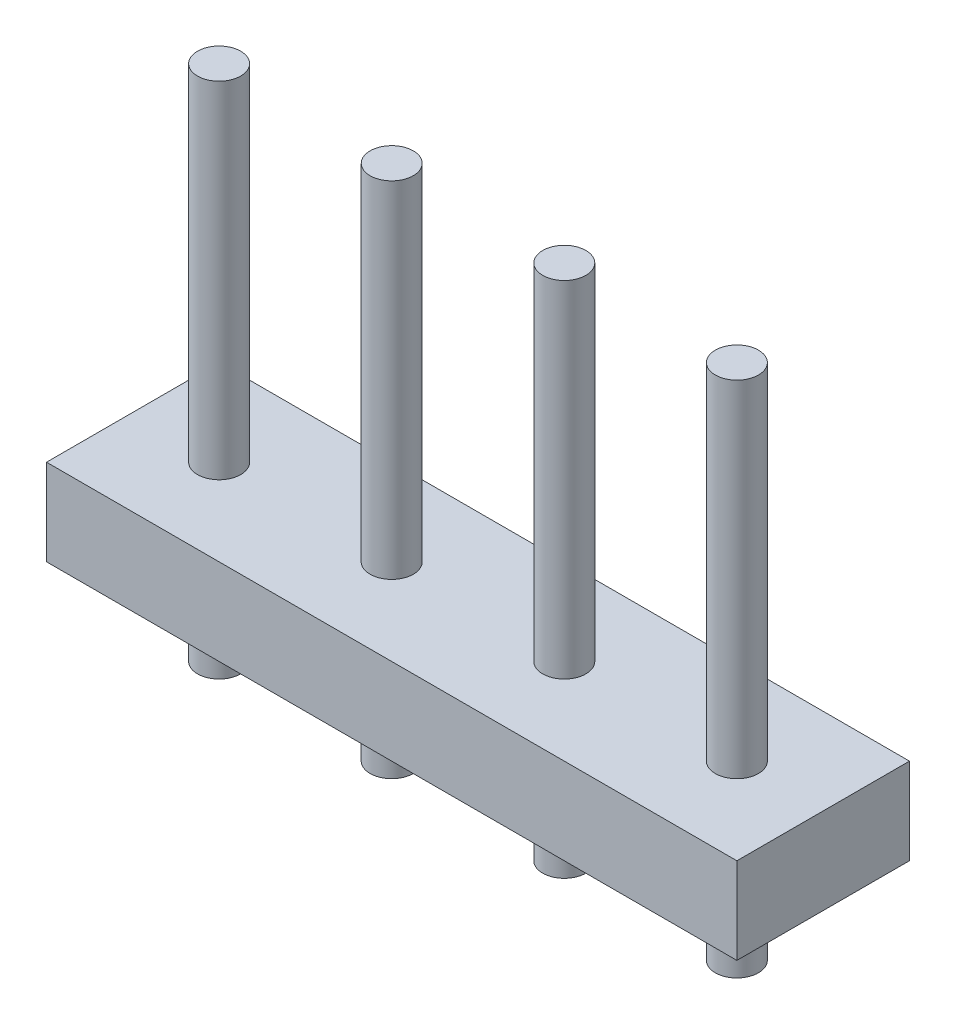
from build123d import *

# Parameters (mm, degrees)
SKETCH1_W           = 10.16
SKETCH1_H           = 2.54
EXTRUDE1_DEPTH      = 1.27
SKETCH2_R           = 0.3175
EXTRUDE2_DEPTH      = 5.08
EXTRUDE2_DEPTH_BACK = 2.54


with BuildPart() as part:
    # Sketch1 → Extrude1 (new body)
    with BuildSketch(Plane(origin=(0, 0, 0), x_dir=(1, 0, 0), z_dir=(0, 1, 0))):
        Rectangle(SKETCH1_W, SKETCH1_H)
    extrude(amount=EXTRUDE1_DEPTH)

    # Sketch2 → Extrude2 (add, two sides)
    with BuildSketch(Plane(origin=(0, 1.27, 0), x_dir=(1, 0, 0), z_dir=(0, 1, 0))) as extrude2_sk:
        with Locations(Location((-1.27, 0, 0), (0, 0, 270))):  # turned: the seam where the file's is
            Circle(SKETCH2_R)
        with Locations(Location((-3.81, 0, 0), (0, 0, 270))):  # turned: the seam where the file's is
            Circle(SKETCH2_R)
        with Locations(Location((1.27, 0, 0), (0, 0, 270))):  # turned: the seam where the file's is
            Circle(SKETCH2_R)
        with Locations(Location((3.81, 0, 0), (0, 0, 270))):  # turned: the seam where the file's is
            Circle(SKETCH2_R)
    extrude(amount=EXTRUDE2_DEPTH)
    extrude(extrude2_sk.sketch, amount=-EXTRUDE2_DEPTH_BACK)


solid = part.part
